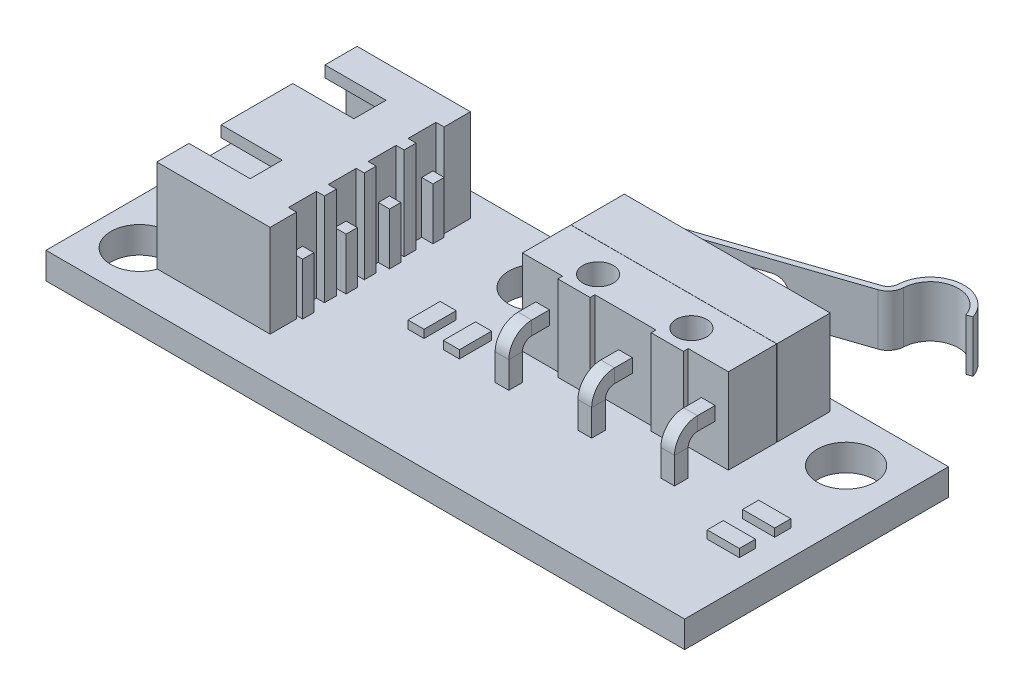
from build123d import *

# Parameters (mm, degrees)
SKETCH1_W           = 39.7
SKETCH1_H           = 16.4
BOSS_EXTRUDE1_DEPTH = 1.65
SKETCH2_W           = 12.8
SKETCH2_H           = 6.63
BOSS_EXTRUDE2_DEPTH = 5.3
SKETCH3_W           = 2.5
SKETCH3_H           = 0.3
SKETCH3_W_2         = 3.8
SKETCH3_W_3         = 12.8
SKETCH3_H_2         = 0.01
CUT_EXTRUDE1_DEPTH  = 5.3
SKETCH4_R           = 0.95
CUT_EXTRUDE2_DEPTH  = 5.3
BOSS_EXTRUDE3_START = -1.1
BOSS_EXTRUDE3_DEPTH = 3
EXTRUDE_THIN1_START = -1
EXTRUDE_THIN1_DEPTH = 3.2
SKETCH7_W           = 7.04
SKETCH7_H           = 12.45
BOSS_EXTRUDE4_DEPTH = 5.75
SKETCH8_R           = 1.7875
CUT_EXTRUDE3_DEPTH  = 1.65
SKETCH10_W          = 11.05
SKETCH10_H          = 4.35
CUT_EXTRUDE4_DEPTH  = 6.04
SKETCH11_W          = 3.8
SKETCH11_H          = 2
CUT_EXTRUDE5_DEPTH  = 0.7
SKETCH12_W          = 0.7
SKETCH12_H          = 0.7
BOSS_EXTRUDE5_DEPTH = 4
CHAMFER1_SIZE       = 0.2
SKETCH14_W          = 0.5
SKETCH14_H          = 1.7375
CUT_EXTRUDE6_DEPTH  = 5.75
SKETCH16_W          = 0.85
SKETCH16_H          = 0.85
CUT_EXTRUDE7_DEPTH  = 0.35
SKETCH19_W          = 0.7
SKETCH19_H          = 6.875
BOSS_EXTRUDE6_DEPTH = 0.7
SKETCH20_W          = 0.85
SKETCH20_H          = 0.85
BOSS_EXTRUDE7_DEPTH = 1.6
CHAMFER2_SIZE       = 0.2
SKETCH21_W          = 2
SKETCH21_H          = 1
SKETCH21_W_2        = 1
SKETCH21_H_2        = 2
BOSS_EXTRUDE8_DEPTH = 0.5


with BuildPart() as part:
    # Sketch1 → Boss-Extrude1 (new body)
    with BuildSketch(Plane(origin=(0, 0, 0), x_dir=(1, 0, 0), z_dir=(0, 1, 0))):
        Rectangle(SKETCH1_W, SKETCH1_H)
    extrude(amount=BOSS_EXTRUDE1_DEPTH)

    # Sketch2 → Boss-Extrude2 (add)
    with BuildSketch(Plane(origin=(0, 1.65, 0), x_dir=(1, 0, 0), z_dir=(0, 1, 0))):
        with Locations((6.8, 4.185)):
            Rectangle(SKETCH2_W, SKETCH2_H)
    extrude(amount=BOSS_EXTRUDE2_DEPTH)

    # Sketch3 → Cut-Extrude1 (cut)
    with BuildSketch(Plane(origin=(0, 6.95, 0), x_dir=(1, 0, 0), z_dir=(0, 1, 0))):
        with Locations((1.65, 1.02)):
            Rectangle(SKETCH3_W, SKETCH3_H)
        with Locations((6.8, 1.02)):
            Rectangle(SKETCH3_W_2, SKETCH3_H)
        with Locations((11.95, 1.02)):
            Rectangle(SKETCH3_W, SKETCH3_H)
        with Locations((6.8, 4.18)):
            Rectangle(SKETCH3_W_3, SKETCH3_H_2)
    extrude(amount=-CUT_EXTRUDE1_DEPTH, mode=Mode.SUBTRACT)

    # Sketch4 → Cut-Extrude2 (cut)
    with BuildSketch(Plane(origin=(0, 6.95, 0), x_dir=(1, 0, 0), z_dir=(0, 1, 0))):
        with Locations((3.9, 2.37)):
            Circle(SKETCH4_R)
        with Locations((9.7, 2.37)):
            Circle(SKETCH4_R)
    extrude(amount=-CUT_EXTRUDE2_DEPTH, mode=Mode.SUBTRACT)

    # Sketch5 → Boss-Extrude3 (add)
    with BuildSketch(Plane(origin=(0, 6.95, 0), x_dir=(1, 0, 0), z_dir=(0, 1, 0)).offset(BOSS_EXTRUDE3_START)):
        with BuildLine():
            Line((3.65, 7.5), (3.65, 7.75))
            ThreePointArc((3.65, 7.75), (4.4, 8.5), (5.15, 7.75))
            Line((5.15, 7.75), (5.15, 7.5))
            ThreePointArc((5.15, 7.5), (4.4, 6.75), (3.65, 7.5))
        make_face()
    extrude(amount=-BOSS_EXTRUDE3_DEPTH)

    # Sketch7 → Boss-Extrude4 (add)
    with BuildSketch(Plane(origin=(0, 1.65, 0), x_dir=(1, 0, 0), z_dir=(0, 1, 0))):
        with Locations((-11.89, 0.475)):
            Rectangle(SKETCH7_W, SKETCH7_H)
    extrude(amount=BOSS_EXTRUDE4_DEPTH)

    # Sketch8 → Cut-Extrude3 (cut)
    with BuildSketch(Plane.XZ):
        with Locations((16.6125, -5.0725)):
            Circle(SKETCH8_R)
        with Locations((-2.5625, -5.0725)):
            Circle(SKETCH8_R)
        with Locations((-17.0625, -5.6125)):
            Circle(SKETCH8_R)
        with Locations((-17.0625, 5.1625)):
            Circle(SKETCH8_R)
    extrude(amount=-CUT_EXTRUDE3_DEPTH, mode=Mode.SUBTRACT)

    # Sketch10 → Cut-Extrude4 (cut)
    with BuildSketch(Plane.ZY.offset(15.41)):
        with Locations((-0.475, 4.525)):
            Rectangle(SKETCH10_W, SKETCH10_H)
    extrude(amount=-CUT_EXTRUDE4_DEPTH, mode=Mode.SUBTRACT)

    # Sketch11 → Cut-Extrude5 (cut)
    with BuildSketch(Plane(origin=(0, 7.4, 0), x_dir=(1, 0, 0), z_dir=(0, 1, 0))):
        with Locations((-13.51, 3.7)):
            Rectangle(SKETCH11_W, SKETCH11_H)
        with Locations((-13.51, -2.75)):
            Rectangle(SKETCH11_W, SKETCH11_H)
    extrude(amount=-CUT_EXTRUDE5_DEPTH, mode=Mode.SUBTRACT)

    # Sketch12 → Boss-Extrude5 (add)
    with BuildSketch(Plane.ZY.offset(9.37)):
        with Locations((-4.525, 4.525)):
            Rectangle(SKETCH12_W, SKETCH12_H)
        with Locations((-1.825, 4.525)):
            Rectangle(SKETCH12_W, SKETCH12_H)
        with Locations((0.875, 4.525)):
            Rectangle(SKETCH12_W, SKETCH12_H)
        with Locations((3.575, 4.525)):
            Rectangle(SKETCH12_W, SKETCH12_H)
    extrude(amount=BOSS_EXTRUDE5_DEPTH)

    # Chamfer1
    chamfer1_edges = [part.edges().sort_by_distance(p)[0] for p in [
        (-13.37, 4.525, -4.875),
        (-13.37, 4.175, -4.525),
        (-13.37, 4.525, -4.175),
        (-13.37, 4.875, -4.525),
        (-13.37, 4.525, -2.175),
        (-13.37, 4.175, -1.825),
        (-13.37, 4.525, -1.475),
        (-13.37, 4.875, -1.825),
        (-13.37, 4.525, 0.525),
        (-13.37, 4.175, 0.875),
        (-13.37, 4.525, 1.225),
        (-13.37, 4.875, 0.875),
        (-13.37, 4.525, 3.225),
        (-13.37, 4.175, 3.575),
        (-13.37, 4.525, 3.925),
        (-13.37, 4.875, 3.575),
    ]]
    chamfer(chamfer1_edges, length=CHAMFER1_SIZE)

    # Sketch14 → Cut-Extrude6 (cut)
    with BuildSketch(Plane(origin=(0, 7.4, 0), x_dir=(1, 0, 0), z_dir=(0, 1, 0))):
        with Locations((-8.62, 4.19125)):
            Rectangle(SKETCH14_W, SKETCH14_H)
        with Locations((-8.62, 1.71375)):
            Rectangle(SKETCH14_W, SKETCH14_H)
        with Locations((-8.62, -0.76375)):
            Rectangle(SKETCH14_W, SKETCH14_H)
        with Locations((-8.62, -3.24125)):
            Rectangle(SKETCH14_W, SKETCH14_H)
    extrude(amount=-CUT_EXTRUDE6_DEPTH, mode=Mode.SUBTRACT)

    # Sweep1: sweep along a path in Sketch17
    with BuildLine(Plane.ZY.offset(-2.9)) as sweep1_path:
        Line((-1.17, 4.3), (-0.07, 4.3))
        ThreePointArc((-0.07, 4.3), (0.637106781, 4.007106781), (0.93, 3.3))
        Line((0.93, 3.3), (0.93, 1.65))
    # Sketch16 → Sweep1 (sweep)
    with BuildSketch(Plane.XY.offset(-1.17)):
        with Locations((1.65, 4.3)):
            Rectangle(SKETCH16_W, SKETCH16_H)
        with Locations((6.8, 4.3)):
            Rectangle(SKETCH16_W, SKETCH16_H)
        with Locations((11.95, 4.3)):
            Rectangle(SKETCH16_W, SKETCH16_H)
    sweep(path=sweep1_path.line)


with BuildPart() as body_2:
    # Sketch6 → Extrude-Thin1 (new body)
    with BuildSketch(Plane(origin=(0, 6.95, 0), x_dir=(1, 0, 0), z_dir=(0, 1, 0)).offset(EXTRUDE_THIN1_START)):
        with BuildLine():
            Line((0.829126789, 7.340655037), (1.303056302, 7.5))
            Line((1.303056302, 7.5), (12.430587103, 11.241307376))
            ThreePointArc((12.430587103, 11.241307376), (12.909711321, 11.586262932), (13.110753947, 12.141363117))
            ThreePointArc((13.110753947, 12.141363117), (14.617563639, 13.791006983), (16.517506588, 12.615414739))
            Line((16.517506588, 12.615414739), (16.849257247, 12.726956213))
            ThreePointArc((16.849257247, 12.726956213), (14.569325708, 14.137666906), (12.761154078, 12.158094266))
            ThreePointArc((12.761154078, 12.158094266), (12.630476371, 11.797279146), (12.319045629, 11.573058034))
            Line((12.319045629, 11.573058034), (1.191514828, 7.831750659))
            Line((1.191514828, 7.831750659), (0.717585316, 7.672405696))
            Line((0.717585316, 7.672405696), (0.829126789, 7.340655037))
        make_face()
    extrude(amount=-EXTRUDE_THIN1_DEPTH)


with BuildPart() as cut_extrude7_tool:
    # Sketch18 → Cut-Extrude7 (new body)
    with BuildSketch(Plane(origin=(-2.244747232, 0, -6.676407859), x_dir=(-0.947859025, 0, 0.318689925), z_dir=(-0.318689925, 0, -0.947859025))):
        with BuildLine():
            Line((-3.125288117, 3.5), (-10.125288117, 3.5))
            ThreePointArc((-10.125288117, 3.5), (-10.975288117, 4.35), (-10.125288117, 5.2))
            Line((-10.125288117, 5.2), (-3.125288117, 5.2))
            Line((-3.125288117, 5.2), (-3.125288117, 3.5))
        make_face()
    extrude(amount=-CUT_EXTRUDE7_DEPTH)


with BuildPart() as part_1:
    add(part.part)

    # Cut-Extrude7: cut by cut_extrude7_tool
    add(cut_extrude7_tool.part, mode=Mode.SUBTRACT)

    # Sketch19 → Boss-Extrude6 (add)
    with BuildSketch(Plane(origin=(-8.87, 0, 0), x_dir=(0, 0, -1), z_dir=(1, 0, 0))):
        with Locations((-3.575, 1.4375)):
            Rectangle(SKETCH19_W, SKETCH19_H)
        with Locations((-0.875, 1.4375)):
            Rectangle(SKETCH19_W, SKETCH19_H)
        with Locations((1.825, 1.4375)):
            Rectangle(SKETCH19_W, SKETCH19_H)
        with Locations((4.525, 1.4375)):
            Rectangle(SKETCH19_W, SKETCH19_H)
    extrude(amount=BOSS_EXTRUDE6_DEPTH)

    # Sketch20 → Boss-Extrude7 (add)
    with BuildSketch(Plane.XZ):
        with Locations((1.65, 0.93)):
            Rectangle(SKETCH20_W, SKETCH20_H)
        with Locations((6.8, 0.93)):
            Rectangle(SKETCH20_W, SKETCH20_H)
        with Locations((11.95, 0.93)):
            Rectangle(SKETCH20_W, SKETCH20_H)
    extrude(amount=BOSS_EXTRUDE7_DEPTH)

    # Chamfer2
    chamfer2_edges = [part_1.edges().sort_by_distance(p)[0] for p in [
        (-8.87, -2, 3.575),
        (-8.52, -2, 3.925),
        (-8.52, -2, 3.225),
        (-8.17, -2, 3.575),
        (-8.87, -2, 0.875),
        (-8.52, -2, 1.225),
        (-8.52, -2, 0.525),
        (-8.17, -2, 0.875),
        (-8.87, -2, -1.825),
        (-8.52, -2, -1.475),
        (-8.52, -2, -2.175),
        (-8.17, -2, -1.825),
        (-8.87, -2, -4.525),
        (-8.52, -2, -4.175),
        (-8.52, -2, -4.875),
        (-8.17, -2, -4.525),
        (1.225, -1.6, 0.93),
        (1.65, -1.6, 0.505),
        (2.075, -1.6, 0.93),
        (1.65, -1.6, 1.355),
        (6.375, -1.6, 0.93),
        (6.8, -1.6, 0.505),
        (7.225, -1.6, 0.93),
        (6.8, -1.6, 1.355),
        (11.525, -1.6, 0.93),
        (11.95, -1.6, 0.505),
        (12.375, -1.6, 0.93),
        (11.95, -1.6, 1.355),
    ]]
    chamfer(chamfer2_edges, length=CHAMFER2_SIZE)

    # Sketch21 → Boss-Extrude8 (add)
    with BuildSketch(Plane(origin=(0, 1.65, 0), x_dir=(1, 0, 0), z_dir=(0, 1, 0))):
        with Locations((17.25, -0.5)):
            Rectangle(SKETCH21_W, SKETCH21_H)
        with Locations((17.25, -2.7)):
            Rectangle(SKETCH21_W, SKETCH21_H)
        with Locations((-3.85, -0.2)):
            Rectangle(SKETCH21_W_2, SKETCH21_H_2)
        with Locations((-1.65, -0.2)):
            Rectangle(SKETCH21_W_2, SKETCH21_H_2)
    extrude(amount=BOSS_EXTRUDE8_DEPTH)


with BuildPart() as body_2_1:
    add(body_2.part)

    # Cut-Extrude7: cut by cut_extrude7_tool
    add(cut_extrude7_tool.part, mode=Mode.SUBTRACT)


solid = Compound([part_1.part, body_2_1.part])
